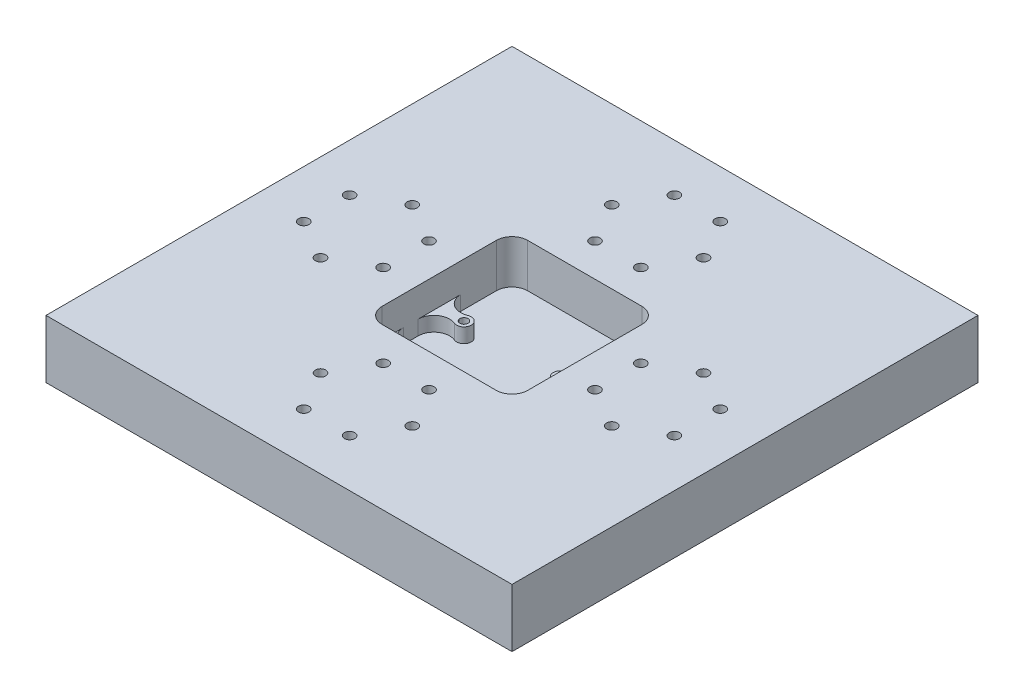
from build123d import *

# Parameters (mm, degrees)
SKETCH1_W             = 101.6
SKETCH1_H             = 101.6
BOSS_EXTRUDE1_DEPTH   = 12.7
F_4_40_TAPPED_HOLE3_D = 2.2606
CIRPATTERN2_COUNT     = 4
SKETCH6_W             = 31.75
SKETCH6_H             = 31.75
CUT_EXTRUDE3_DEPTH    = 9.525
FILLET1_R             = 3.429
F_2_56_TAPPED_HOLE2_D = 1.778
SKETCH17_R            = 0.889
BOSS_EXTRUDE3_DEPTH   = 3.175


with BuildPart() as part:
    # Sketch1 → Boss-Extrude1 (new body)
    with BuildSketch(Plane(origin=(0, 0, 0), x_dir=(1, 0, 0), z_dir=(0, 1, 0))):
        Rectangle(SKETCH1_W, SKETCH1_H)
    extrude(amount=BOSS_EXTRUDE1_DEPTH)

    # 4-40 Tapped Hole3 (through all)
    with Locations(Plane(origin=(0, 12.7, 0), x_dir=(1, 0, 0), z_dir=(0, 1, 0))):
        with Locations((-5, 23.089746), (5, 23.089746), (10, 31.75), (5, 40.410254), (-5, 40.410254), (-10, 31.75)):
            f_4_40_tapped_hole3 = Hole(F_4_40_TAPPED_HOLE3_D / 2)

    # CirPattern2: 4-40 Tapped Hole3 ×4 about axis
    cirpattern2_axis = Axis((0, 0, 0), (0, 1, 0))
    for i in range(1, CIRPATTERN2_COUNT):
        add(f_4_40_tapped_hole3.rotate(cirpattern2_axis, i * 360 / CIRPATTERN2_COUNT), mode=Mode.SUBTRACT)

    # Sketch6 → Cut-Extrude3 (cut)
    with BuildSketch(Plane(origin=(0, 12.7, 0), x_dir=(1, 0, 0), z_dir=(0, 1, 0))):
        Rectangle(SKETCH6_W, SKETCH6_H)
    extrude(amount=-CUT_EXTRUDE3_DEPTH, mode=Mode.SUBTRACT)

    # Fillet1
    fillet1_edges = [part.edges().sort_by_distance(p)[0] for p in [
        (15.875, 7.9375, -15.875),
        (15.875, 7.9375, 15.875),
        (-15.875, 7.9375, 15.875),
        (-15.875, 7.9375, -15.875),
    ]]
    fillet(fillet1_edges, radius=FILLET1_R)

    # 2-56 Tapped Hole2 (through all)
    with Locations(Plane(origin=(-26.456272, 3.175, -55.350427), x_dir=(1, 0, 0), z_dir=(0, 1, 0))):
        with Locations((15.924749, -55.291806), (15.924749, -67.791806), (36.924749, -67.791806), (36.924749, -55.291806)):
            Hole(F_2_56_TAPPED_HOLE2_D / 2)

    # Sketch17 → Boss-Extrude3 (add)
    with BuildSketch(Plane(origin=(0, 3.175, 0), x_dir=(1, 0, 0), z_dir=(0, 1, 0))):
        with BuildLine():
            Line((-12.446, -15.875), (-5.515026, -15.875))
            ThreePointArc((-5.515026, -15.875), (-7.940811, -14.869552), (-8.944024, -12.442842))
            ThreePointArc((-8.944024, -12.442842), (-9.6482, -11.122328), (-11.137371, -10.974033))
            ThreePointArc((-11.137371, -10.974033), (-14.352666, -10.654593), (-15.875, -7.804564))
            Line((-15.875, -7.804564), (-15.875, -12.446))
            ThreePointArc((-15.875, -12.446), (-14.870669, -14.870669), (-12.446, -15.875))
        make_face()
        with Locations(Location((-10.531524, -12.441379, 0), (0, 0, 270))):  # turned: the seam where the file's is
            Circle(SKETCH17_R, mode=Mode.SUBTRACT)
        with BuildLine():
            Line((-15.875, 4.695436), (-15.875, -4.578194))
            ThreePointArc((-15.875, -4.578194), (-14.352666, -1.728165), (-11.137371, -1.408726))
            ThreePointArc((-11.137371, -1.408726), (-8.944024, 0.058621), (-11.137371, 1.525967))
            ThreePointArc((-11.137371, 1.525967), (-14.352666, 1.845407), (-15.875, 4.695436))
        make_face()
        with Locations(Location((-10.531524, 0.058621, 0), (0, 0, 270))):  # turned: the seam where the file's is
            Circle(SKETCH17_R, mode=Mode.SUBTRACT)
    boss_extrude3 = extrude(amount=BOSS_EXTRUDE3_DEPTH)

    # Mirror2: Boss-Extrude3 across plane
    add(boss_extrude3.mirror(Plane(origin=(0, 0, 0), x_dir=(0, 0, 1), z_dir=(1, 0, 0))))


solid = part.part
